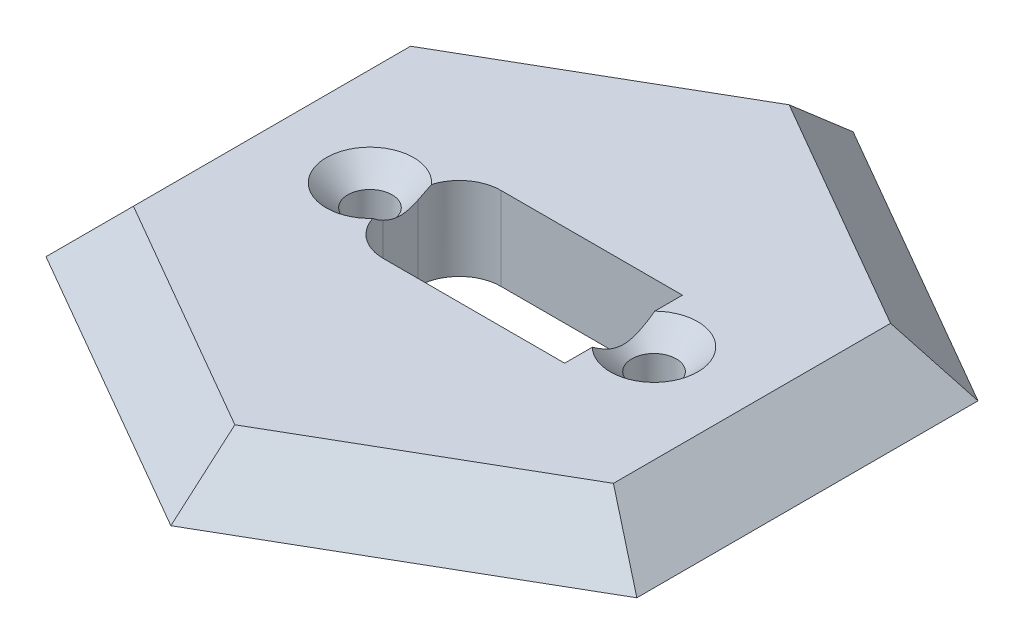
from build123d import *

# Parameters (mm, degrees)
SKETCH1_R                                           = 26
BOSS_EXTRUDE1_DEPTH                                 = 4
SKETCH3_R                                           = 17
BOSS_EXTRUDE2_DEPTH                                 = 2
CUT_EXTRUDE1_DEPTH                                  = 20
SKETCH4_R                                           = 1.6
CUT_EXTRUDE2_DEPTH                                  = 10
SKETCH6_OUTSIDE_W                                   = 88.756
SKETCH6_OUTSIDE_H                                   = 88.756
CUT_EXTRUDE3_DEPTH                                  = 10
CUT_EXTRUDE3_TAPER                                  = 45
CSK_FOR_M3_COUNTERSUNK_FLAT_HEAD_SCREW2_D           = 3.2
CSK_FOR_M3_COUNTERSUNK_FLAT_HEAD_SCREW2_CSINK_D     = 6.3
CSK_FOR_M3_COUNTERSUNK_FLAT_HEAD_SCREW2_CSINK_ANGLE = 90


with BuildPart() as part:
    # Sketch1 → Boss-Extrude1 (new body)
    with BuildSketch(Plane(origin=(0, 0, 0), x_dir=(1, 0, 0), z_dir=(0, 1, 0))):
        Circle(SKETCH1_R)
    extrude(amount=BOSS_EXTRUDE1_DEPTH)

    # Sketch3 → Boss-Extrude2 (add)
    with BuildSketch(Plane.XZ):
        Circle(SKETCH3_R)
    extrude(amount=BOSS_EXTRUDE2_DEPTH)

    # Sketch2 → Cut-Extrude1 (cut)
    with BuildSketch(Plane(origin=(0, 4, 0), x_dir=(1, 0, 0), z_dir=(0, 1, 0))):
        with BuildLine():
            Line((-5.05, -4.25), (8.05, -4.25))
            Line((8.05, -4.25), (8.05, 4.25))
            Line((8.05, 4.25), (-5.05, 4.25))
            ThreePointArc((-5.05, 4.25), (-7.171320344, 3.371320344), (-8.05, 1.25))
            Line((-8.05, 1.25), (-8.05, -1.25))
            ThreePointArc((-8.05, -1.25), (-7.171320344, -3.371320344), (-5.05, -4.25))
        make_face()
    extrude(amount=-CUT_EXTRUDE1_DEPTH, mode=Mode.SUBTRACT)

    # Sketch4 → Cut-Extrude2 (cut)
    with BuildSketch(Plane(origin=(0, 4, 0), x_dir=(1, 0, 0), z_dir=(0, 1, 0))):
        with Locations((-10.25, 0)):
            Circle(SKETCH4_R)
        with Locations((10.25, 0)):
            Circle(SKETCH4_R)
    extrude(amount=-CUT_EXTRUDE2_DEPTH, mode=Mode.SUBTRACT)

    # Sketch6 outside → Cut-Extrude3 (cut)
    with BuildSketch(Plane(origin=(0, 4, 0), x_dir=(1, 0, 0), z_dir=(0, 1, 0))):
        Rectangle(SKETCH6_OUTSIDE_W, SKETCH6_OUTSIDE_H)
        Polygon((0, 20), (-17.320508076, 10), (-17.320508076, -10), (0, -20), (17.320508076, -10), (17.320508076, 10), align=None, mode=Mode.SUBTRACT)
    extrude(amount=-CUT_EXTRUDE3_DEPTH, taper=CUT_EXTRUDE3_TAPER, mode=Mode.SUBTRACT)

    # CSK for M3 Countersunk Flat Head Screw2 (through all)
    with Locations(Plane(origin=(0, 4, 0), x_dir=(1, 0, 0), z_dir=(0, 1, 0))):
        with Locations((-10.25, 0), (10.25, 0)):
            CounterSinkHole(CSK_FOR_M3_COUNTERSUNK_FLAT_HEAD_SCREW2_D / 2, CSK_FOR_M3_COUNTERSUNK_FLAT_HEAD_SCREW2_CSINK_D / 2, counter_sink_angle=CSK_FOR_M3_COUNTERSUNK_FLAT_HEAD_SCREW2_CSINK_ANGLE)


solid = part.part
